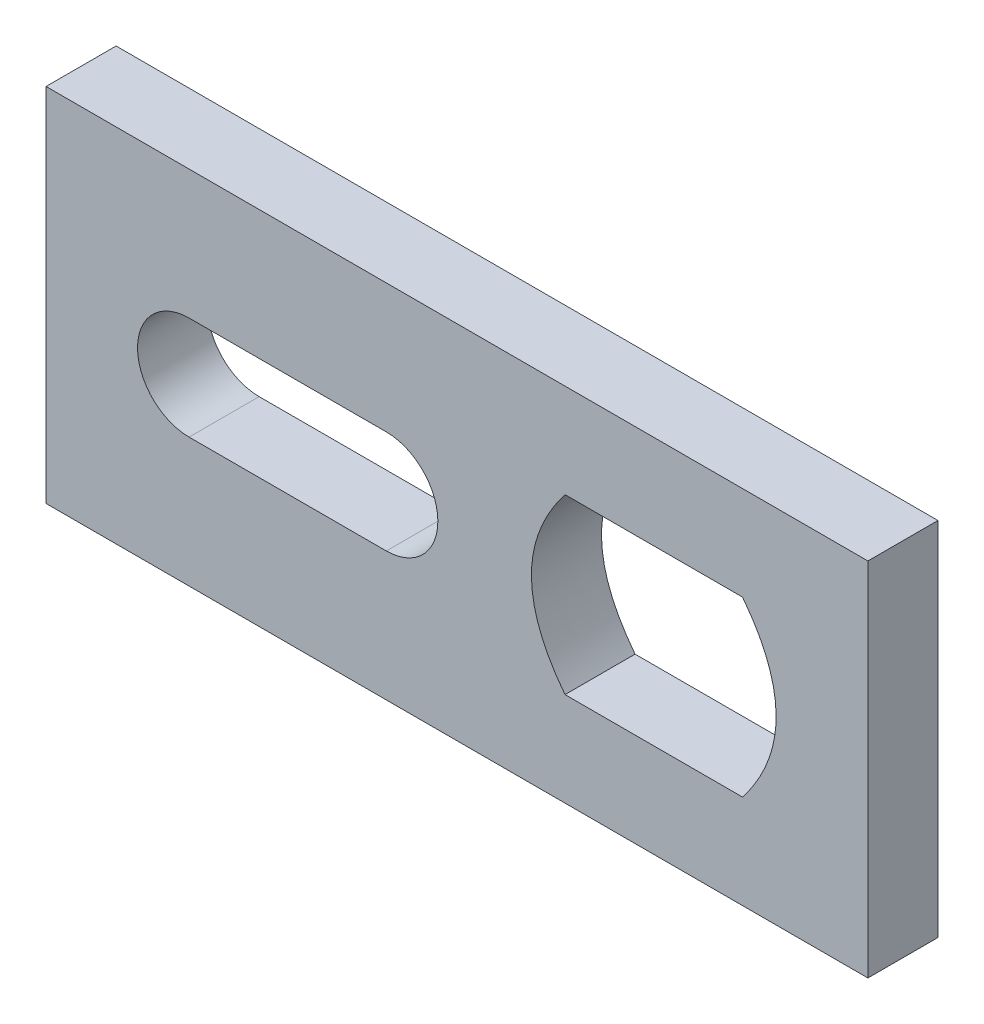
from build123d import *

# Parameters (mm, degrees)
BOSS_EXTRUDE1_DEPTH = 5.81


with BuildPart() as part:
    # Sketch2 → Boss-Extrude1 (new body)
    with BuildSketch(Plane.XY):
        Polygon((0, 29.95), (0, 14.975), (0, 0), (68.15, 0), (68.15, 14.975), (68.15, 29.95), align=None)
        with BuildLine():
            ThreePointArc((11.86, 10.7), (8.83711851, 11.95211851), (7.585, 14.975))
            ThreePointArc((7.585, 14.975), (8.83711851, 17.99788149), (11.86, 19.25))
            Line((11.86, 19.25), (20.035, 19.25))
            Line((20.035, 19.25), (28.215, 19.25))
            ThreePointArc((28.215, 19.25), (31.23788149, 17.99788149), (32.49, 14.975))
            ThreePointArc((32.49, 14.975), (31.23788149, 11.95211851), (28.215, 10.7))
            Line((28.215, 10.7), (20.035, 10.7))
            Line((20.035, 10.7), (11.86, 10.7))
        make_face(mode=Mode.SUBTRACT)
        with BuildLine():
            add(Edge.make_bspline(
                [(57.755, 22.155), (60.54, 18.565), (60.54, 14.975)],
                knots=[0, 0, 0, 0.5, 0.5, 0.5], degree=2))
            add(Edge.make_bspline(
                [(60.54, 14.975), (60.54, 11.385), (57.755, 7.795)],
                knots=[0.5, 0.5, 0.5, 1, 1, 1], degree=2))
            Line((57.755, 7.795), (50.395, 7.795))
            Line((50.395, 7.795), (43.035, 7.795))
            add(Edge.make_bspline(
                [(43.035, 7.795), (40.25, 11.385), (40.25, 14.975)],
                knots=[0, 0, 0, 0.5, 0.5, 0.5], degree=2))
            add(Edge.make_bspline(
                [(40.25, 14.975), (40.25, 18.565), (43.035, 22.155)],
                knots=[0.5, 0.5, 0.5, 1, 1, 1], degree=2))
            Line((43.035, 22.155), (50.395, 22.155))
            Line((50.395, 22.155), (57.755, 22.155))
        make_face(mode=Mode.SUBTRACT)
    extrude(amount=BOSS_EXTRUDE1_DEPTH)


solid = part.part
